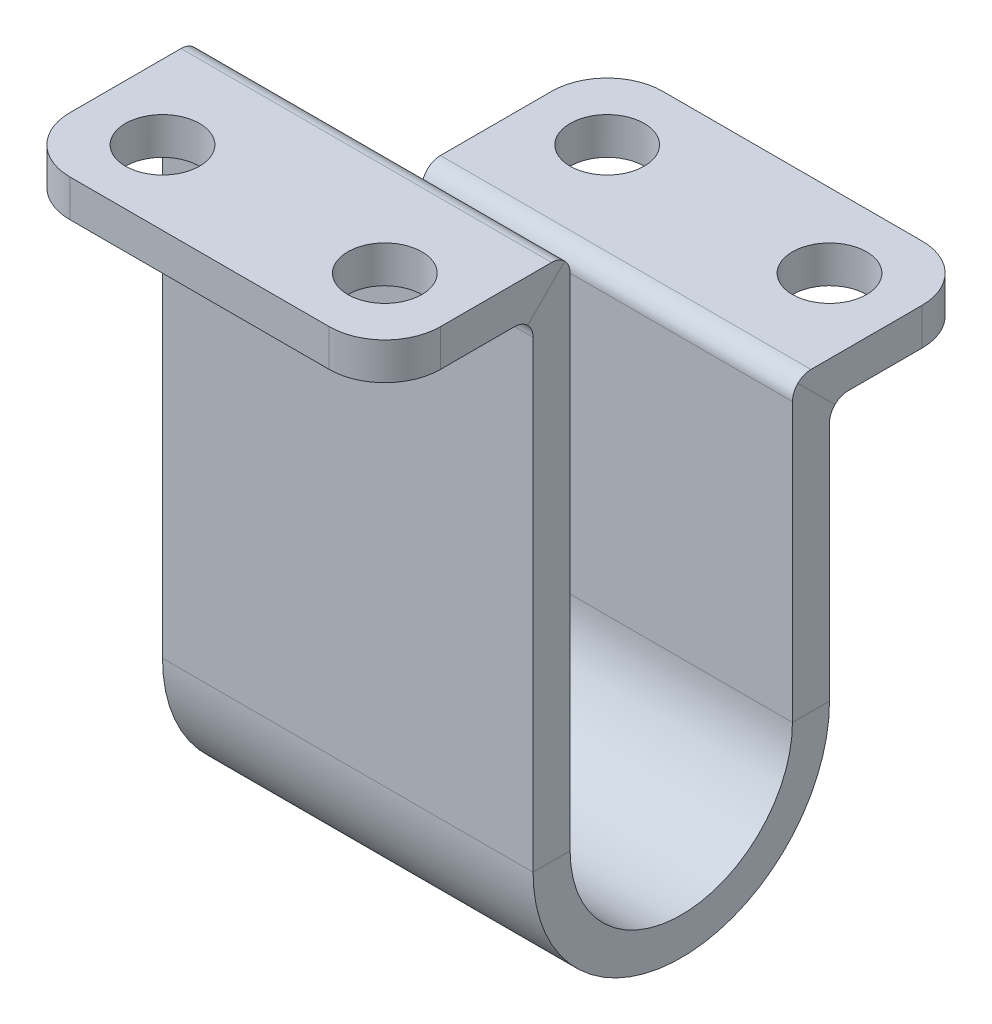
from build123d import *

# Parameters (mm, degrees)
SKETCH2_W          = 50
SKETCH2_H          = 5
FILLET2_R          = 2.5
SKETCH3_R          = 5
CUT_EXTRUDE1_DEPTH = 50
FILLET3_R          = 7.5


with BuildPart() as part:
    # Sweep1: sweep along a path in Sketch1
    with BuildLine(Plane(origin=(0, 0, 0), x_dir=(0, 0, -1), z_dir=(1, 0, 0))) as sweep1_path:
        Line((0, 0), (22.5, 0))
        Line((22.5, 0), (22.5, -67.5))
        ThreePointArc((22.5, -67.5), (40, -85), (57.5, -67.5))
        Line((57.5, -67.5), (57.5, -30))
        Line((57.5, -30), (80, -30))
    # Sketch2 → Sweep1 (sweep)
    with BuildSketch(Plane.XY):
        Rectangle(SKETCH2_W, SKETCH2_H)
    sweep(path=sweep1_path.line, transition=Transition.RIGHT)

    # Fillet2
    fillet2_edges = [part.edges().sort_by_distance(p)[0] for p in [
        (0, 2.5, -25),
        (0, -2.5, -20),
        (0, -27.5, -55),
        (0, -32.5, -60),
    ]]
    fillet(fillet2_edges, radius=FILLET2_R)

    # Sketch3 → Cut-Extrude1 (cut)
    with BuildSketch(Plane(origin=(0, 2.5, 0), x_dir=(1, 0, 0), z_dir=(0, 1, 0))):
        with Locations((-15, 70)):
            Circle(SKETCH3_R)
        with Locations((15, 70)):
            Circle(SKETCH3_R)
        with Locations((15, 10)):
            Circle(SKETCH3_R)
        with Locations((-15, 10)):
            Circle(SKETCH3_R)
    extrude(amount=-CUT_EXTRUDE1_DEPTH, mode=Mode.SUBTRACT)

    # Fillet3
    fillet3_edges = [part.edges().sort_by_distance(p)[0] for p in [
        (25, 0, 0),
        (-25, -30, -80),
        (25, -30, -80),
        (-25, 0, 0),
    ]]
    fillet(fillet3_edges, radius=FILLET3_R)


solid = part.part
